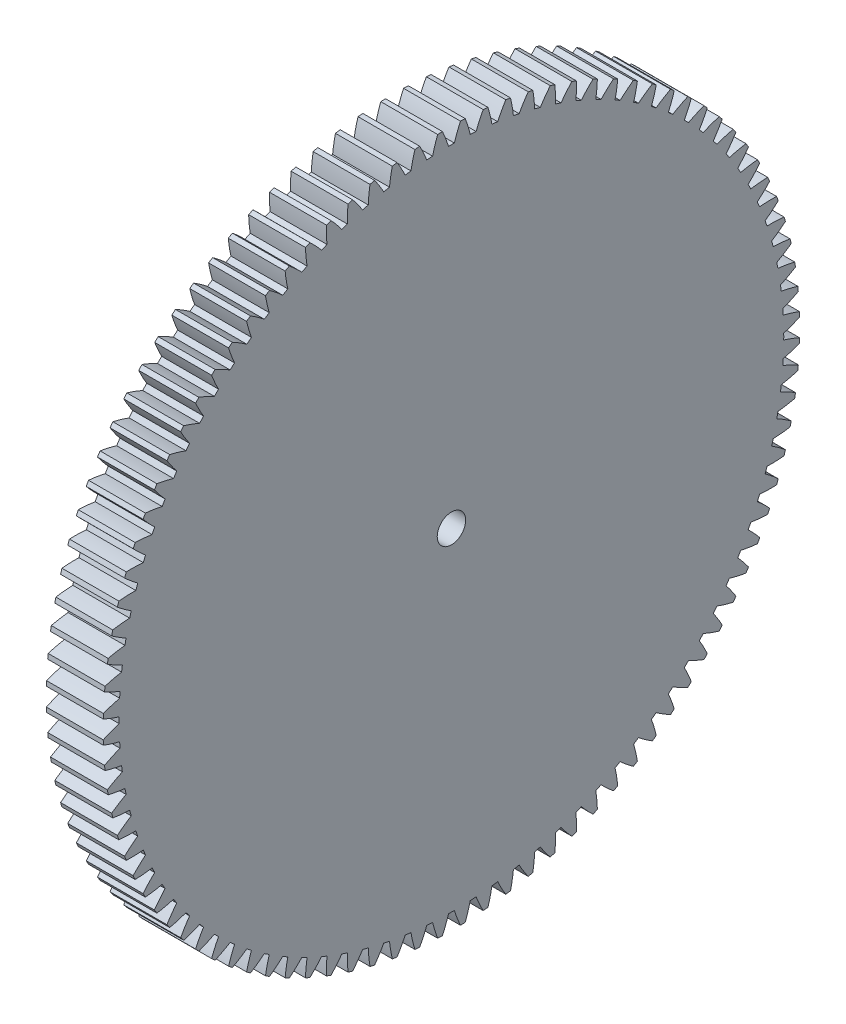
from build123d import *

# Parameters (mm, degrees)
BASPROSKE_W     = 10
BASPROSKE_H     = 61.25
TOOTHCUT_DEPTH  = 88.195900133
TEETHCUTS_COUNT = 96
TEETHCUTS_ANGLE = 356.25
BORSKE_R        = 2.5
BORE_DEPTH      = 50.0000508


with BuildPart() as part:
    # BasProSke → Base-Revolve (revolve)
    with BuildSketch(Plane(origin=(0, 0, 0), x_dir=(1, 0, 0), z_dir=(0, 1, 0)), mode=Mode.PRIVATE) as base_revolve_sk:
        with Locations((5, 30.625)):
            Rectangle(BASPROSKE_W, BASPROSKE_H)
    revolve(base_revolve_sk.sketch.rotate(Axis((-10, 0, 0), (1, 0, 0)), 180), axis=Axis((-10, 0, 0), (1, 0, 0)))

    # TooCutSke → ToothCut (cut, through all)
    with BuildSketch(Plane(origin=(0, 0, 0), x_dir=(0, 0, -1), z_dir=(1, 0, 0))):
        with BuildLine():
            ThreePointArc((0.51539922, 58.434227092), (0, 58.4365), (-0.51539922, 58.434227092))
            ThreePointArc((-0.51539922, 58.434227092), (-1.010588318, 59.861428333), (-1.59458637, 61.254648309))
            ThreePointArc((-1.59458637, 61.254648309), (0, 61.2754), (1.59458637, 61.254648309))
            ThreePointArc((1.59458637, 61.254648309), (1.010588318, 59.861428333), (0.51539922, 58.434227092))
        make_face()
    toothcut = extrude(amount=TOOTHCUT_DEPTH, mode=Mode.SUBTRACT)

    # TeethCuts: ToothCut ×96 about axis
    teethcuts_axis = Axis((-10, 0, 0), (1, 0, 0))
    for i in range(1, TEETHCUTS_COUNT):
        add(toothcut.rotate(teethcuts_axis, i * TEETHCUTS_ANGLE / (TEETHCUTS_COUNT - 1)), mode=Mode.SUBTRACT)

    # BorSke → Bore (cut, symmetric)
    with BuildSketch(Plane(origin=(0, 0, 0), x_dir=(0, 0, -1), z_dir=(1, 0, 0))):
        with Locations(Location((0, 0, 0), (0, 0, 180))):
            Circle(BORSKE_R)
    extrude(amount=BORE_DEPTH, both=True, mode=Mode.SUBTRACT)


solid = part.part
